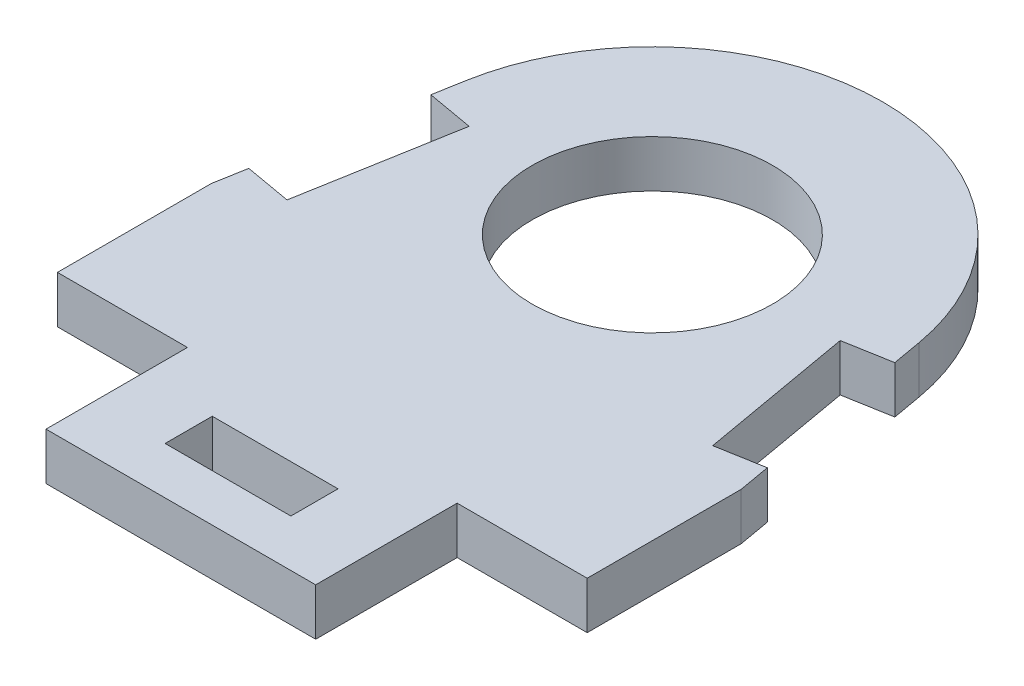
from build123d import *

# Parameters (mm, degrees)
SKETCH1_R           = 7.65
SKETCH1_W           = 8
SKETCH1_H           = 3
BOSS_EXTRUDE1_DEPTH = 1.5


with BuildPart() as part:
    # Sketch1 → Boss-Extrude1 (new, symmetric)
    with BuildSketch(Plane(origin=(0, 0, 0), x_dir=(1, 0, 0), z_dir=(0, 1, 0))):
        with BuildLine():
            Line((-16.852566459, 9.790333805), (-16.852566459, 0))
            Line((-16.852566459, 0), (-8.578866459, 0))
            Line((-8.578866459, 0), (-8.578866459, -9))
            Line((-8.578866459, -9), (8.578866459, -9))
            Line((8.578866459, -9), (8.578866459, 0))
            Line((8.578866459, 0), (16.852566459, 0))
            Line((16.852566459, 0), (16.852566459, 9.790333805))
            Line((16.852566459, 9.790333805), (16.495088327, 11.817693036))
            Line((16.495088327, 11.817693036), (13.540665068, 11.296748503))
            Line((13.540665068, 11.296748503), (11.804183291, 21.144826033))
            Line((11.804183291, 21.144826033), (14.75860655, 21.665770566))
            Line((14.75860655, 21.665770566), (14.427433582, 23.543945803))
            ThreePointArc((14.427433582, 23.543945803), (0, 35.65), (-14.427433582, 23.543945803))
            Line((-14.427433582, 23.543945803), (-14.75860655, 21.665770566))
            Line((-14.75860655, 21.665770566), (-11.804183291, 21.144826033))
            Line((-11.804183291, 21.144826033), (-13.540665068, 11.296748503))
            Line((-13.540665068, 11.296748503), (-16.495088327, 11.817693036))
            Line((-16.495088327, 11.817693036), (-16.852566459, 9.790333805))
        make_face()
        with Locations((0, 21)):
            Circle(SKETCH1_R, mode=Mode.SUBTRACT)
        with Locations((0, -4.5)):
            Rectangle(SKETCH1_W, SKETCH1_H, mode=Mode.SUBTRACT)
    extrude(amount=BOSS_EXTRUDE1_DEPTH, both=True)


solid = part.part
